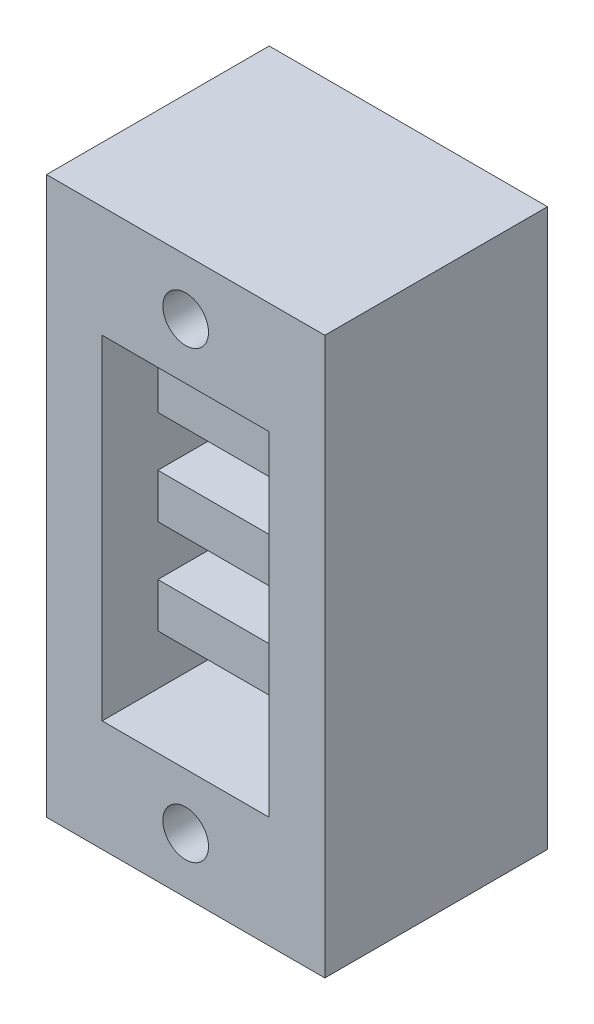
from build123d import *

# Parameters (mm, degrees)
SKETCH1_W           = 12.7
SKETCH1_H           = 10.16
BOSS_EXTRUDE1_DEPTH = 25.4
SKETCH2_W           = 7.62
SKETCH2_H           = 15.24
CUT_EXTRUDE1_DEPTH  = 7.62
SKETCH3_W           = 5.08
SKETCH3_H           = 2.032
BOSS_EXTRUDE2_DEPTH = 7.62
SKETCH4_W           = 7.62
SKETCH4_H           = 2.286
CUT_EXTRUDE2_DEPTH  = 3.54
SKETCH5_R           = 1.0414
CUT_EXTRUDE4_DEPTH  = 11.16


with BuildPart() as part:
    # Sketch1 → Boss-Extrude1 (new body)
    with BuildSketch(Plane(origin=(0, 0, 0), x_dir=(1, 0, 0), z_dir=(0, 1, 0))):
        Rectangle(SKETCH1_W, SKETCH1_H)
    extrude(amount=BOSS_EXTRUDE1_DEPTH)

    # Sketch2 → Cut-Extrude1 (cut)
    with BuildSketch(Plane.XY.offset(5.08)):
        with Locations((0, 12.7)):
            Rectangle(SKETCH2_W, SKETCH2_H)
    extrude(amount=-CUT_EXTRUDE1_DEPTH, mode=Mode.SUBTRACT)

    # Sketch3 → Boss-Extrude2 (add)
    with BuildSketch(Plane.ZY.offset(-3.81)):
        with Locations((0, 12.7)):
            Rectangle(SKETCH3_W, SKETCH3_H)
        with Locations((0, 8.382)):
            Rectangle(SKETCH3_W, SKETCH3_H)
        with Locations((0, 17.018)):
            Rectangle(SKETCH3_W, SKETCH3_H)
    extrude(amount=BOSS_EXTRUDE2_DEPTH)

    # Sketch4 → Cut-Extrude2 (cut, through all)
    with BuildSketch(Plane.XY.offset(-2.54)):
        with Locations((0, 6.223)):
            Rectangle(SKETCH4_W, SKETCH4_H)
    extrude(amount=-CUT_EXTRUDE2_DEPTH, mode=Mode.SUBTRACT)

    # Sketch5 → Cut-Extrude4 (cut, through all)
    with BuildSketch(Plane.XY.offset(5.08)):
        with Locations((0, 2.54)):
            Circle(SKETCH5_R)
        with Locations((0, 22.86)):
            Circle(SKETCH5_R)
    extrude(amount=-CUT_EXTRUDE4_DEPTH, mode=Mode.SUBTRACT)


solid = part.part
